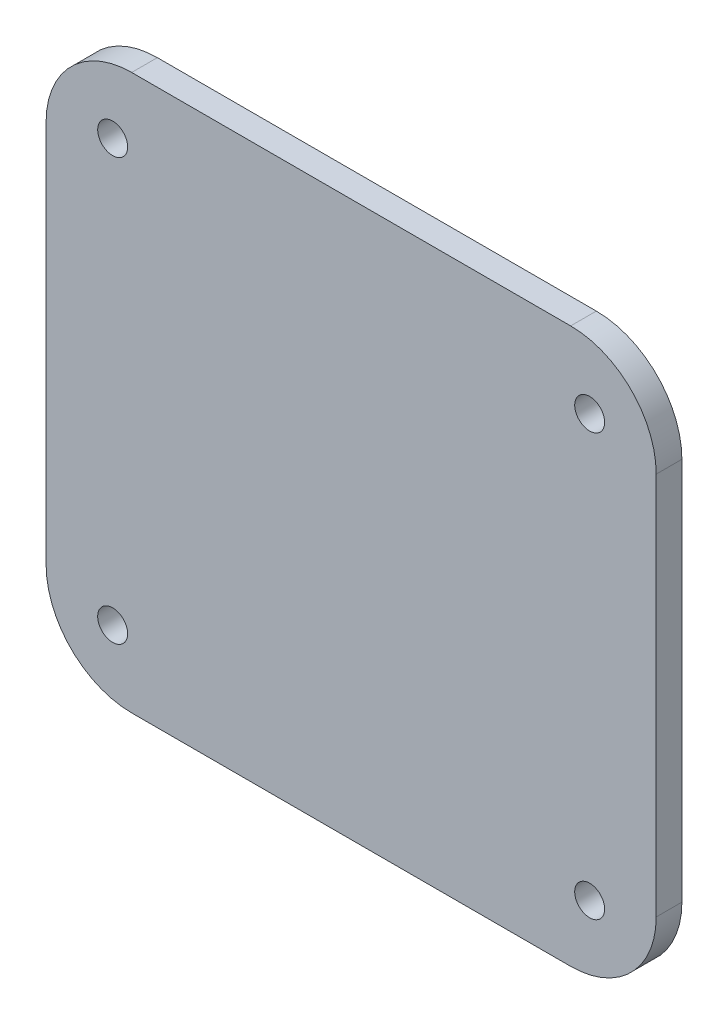
from build123d import *

# Parameters (mm, degrees)
SKETCH_1_W      = 71.296296296
SKETCH_1_H      = 64.814814815
SKETCH_1_R      = 1.75
SKETCH_1_W_2    = 45.37037037
SKETCH_1_H_2    = 38.888888889
EXTRUDE_1_DEPTH = 3
FILLET_1_R      = 10


with BuildPart() as part:
    # 草图1 → 凸台-拉伸1 (new body)
    with BuildSketch(Plane.XY):
        with Locations((0.329915923, 0.017888572)):
            Rectangle(SKETCH_1_W, SKETCH_1_H)
        with Locations((-27.540454447, -24.611741059)):
            Circle(SKETCH_1_R, mode=Mode.SUBTRACT)
        with Locations((28.200286294, -24.611741059)):
            Circle(SKETCH_1_R, mode=Mode.SUBTRACT)
        with Locations((28.200286294, 24.647518201)):
            Circle(SKETCH_1_R, mode=Mode.SUBTRACT)
        with Locations((-27.540454447, 24.647518201)):
            Circle(SKETCH_1_R, mode=Mode.SUBTRACT)
        with Locations((0.329915923, 0.017888572)):
            Rectangle(SKETCH_1_W_2, SKETCH_1_H_2, mode=Mode.SUBTRACT)
        with Locations((0.329915923, 0.017888572)):
            Rectangle(SKETCH_1_W_2, SKETCH_1_H_2)
    extrude(amount=EXTRUDE_1_DEPTH)

    # 圆角1
    fillet_1_edges = [part.edges().sort_by_distance(p)[0] for p in [
        (35.978064071, 32.425295979, 1.5),
        (35.978064071, -32.389518836, 1.5),
        (-35.318232225, -32.389518836, 1.5),
        (-35.318232225, 32.425295979, 1.5),
    ]]
    fillet(fillet_1_edges, radius=FILLET_1_R)


solid = part.part
